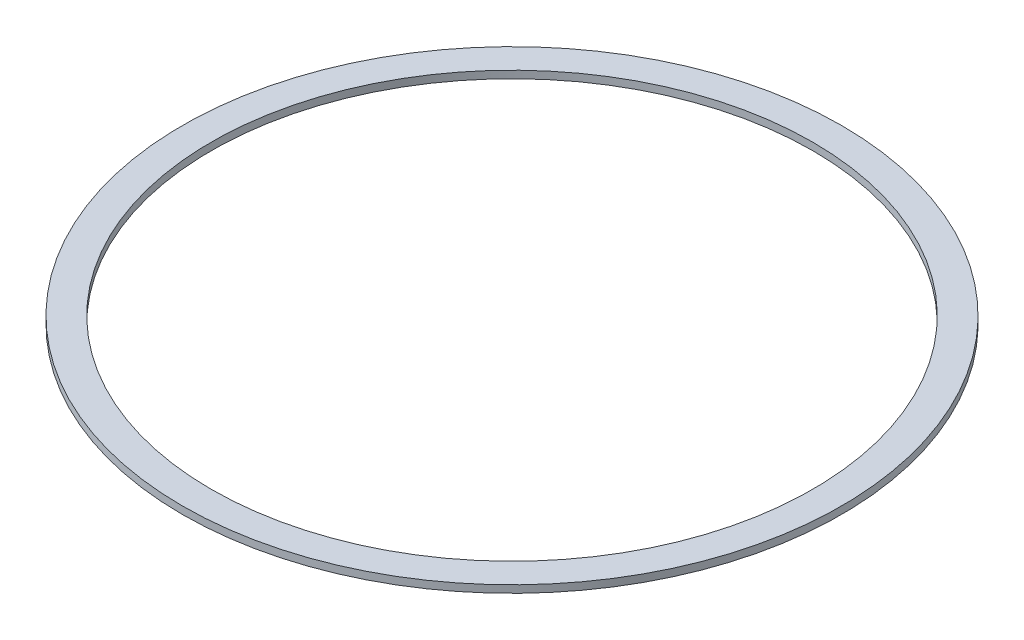
from build123d import *

# Parameters (mm, degrees)
SKETCH1_R           = 80
SKETCH1_R_2         = 73
BOSS_EXTRUDE1_DEPTH = 1.8


with BuildPart() as part:
    # Sketch1 → Boss-Extrude1 (new body)
    with BuildSketch(Plane(origin=(0, 0, 0), x_dir=(1, 0, 0), z_dir=(0, 1, 0))):
        Circle(SKETCH1_R)
        Circle(SKETCH1_R_2, mode=Mode.SUBTRACT)
    extrude(amount=BOSS_EXTRUDE1_DEPTH)


solid = part.part
